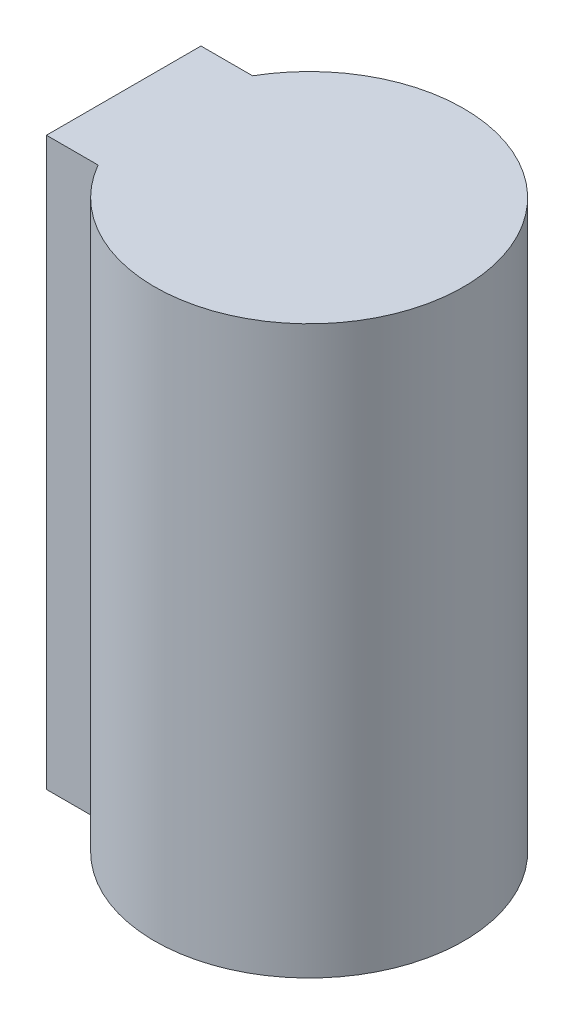
from build123d import *

# Parameters (mm, degrees)
BASIS_DEPTH = 110


with BuildPart() as part:
    # Skizze1 → Basis (new body)
    with BuildSketch(Plane(origin=(0, 0, 0), x_dir=(1, 0, 0), z_dir=(0, 1, 0))):
        with BuildLine():
            Line((-36, 15), (-36, -15))
            Line((-36, -15), (-25.980762114, -15))
            ThreePointArc((-25.980762114, -15), (30, 0), (-25.980762114, 15))
            Line((-25.980762114, 15), (-36, 15))
        make_face()
    extrude(amount=BASIS_DEPTH)


solid = part.part
